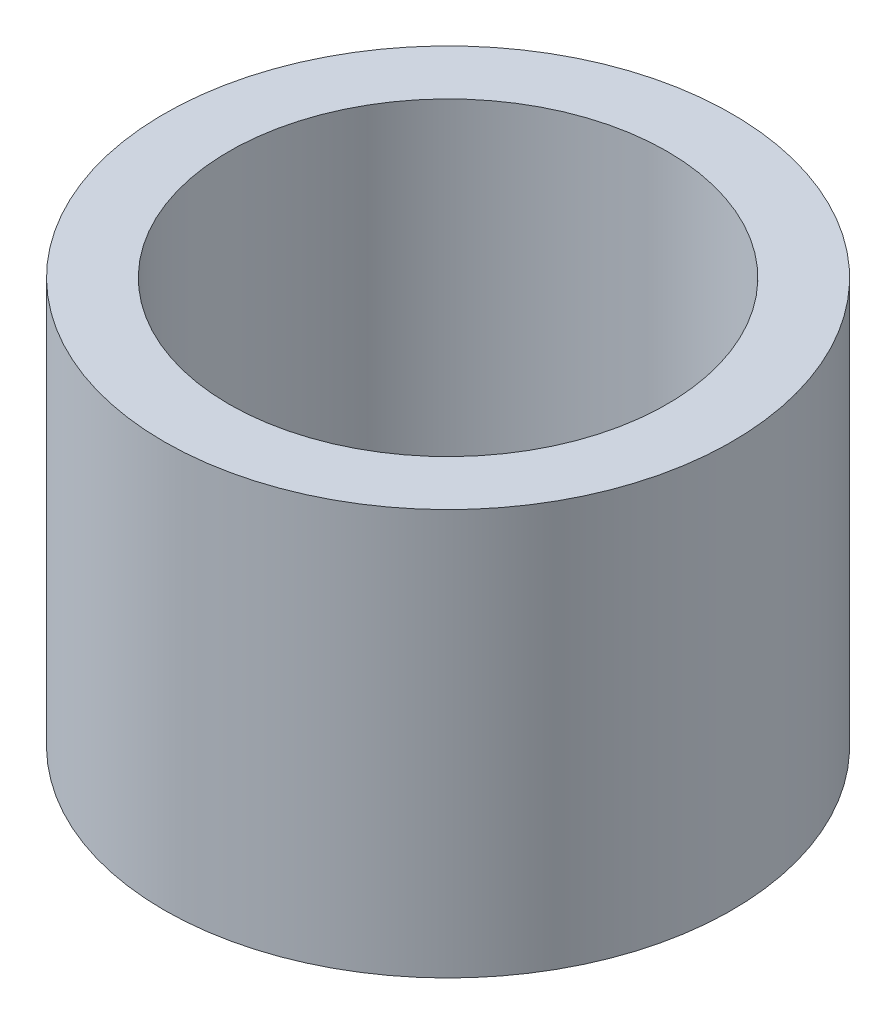
from build123d import *

# Parameters (mm, degrees)
SKETCH2_R           = 3.5
SKETCH2_R_2         = 2.7
BOSS_EXTRUDE1_DEPTH = 5


with BuildPart() as part:
    # Sketch2 → Boss-Extrude1 (new body)
    with BuildSketch(Plane(origin=(0, 0, 0), x_dir=(1, 0, 0), z_dir=(0, 1, 0))):
        Circle(SKETCH2_R)
        Circle(SKETCH2_R_2, mode=Mode.SUBTRACT)
    extrude(amount=BOSS_EXTRUDE1_DEPTH)


solid = part.part
